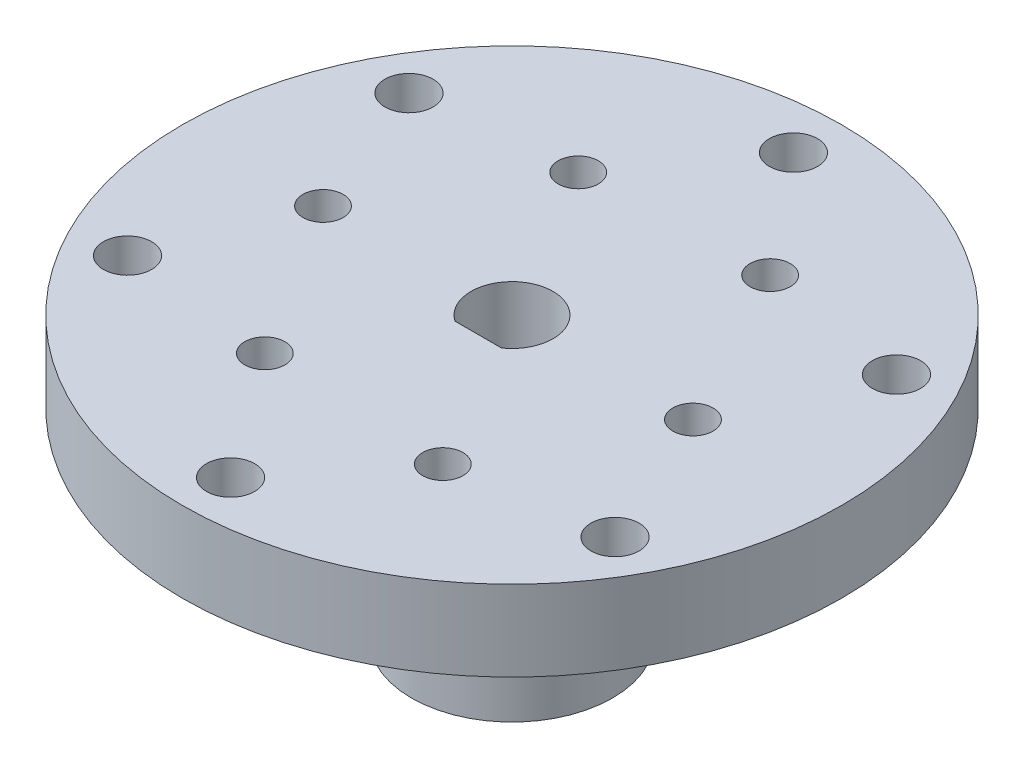
from build123d import *

# Parameters (mm, degrees)
SKETCH1_R               = 12.5
SKETCH1_R_2             = 5.1
BOSS_EXTRUDE1_DEPTH     = 15
SKETCH2_R               = 41
SKETCH2_R_2             = 5.1
BOSS_EXTRUDE2_DEPTH     = 20
SKETCH3_R               = 3
CUT_EXTRUDE1_DEPTH      = 36
BOSS_EXTRUDE3_DEPTH     = 35
SKETCH5_R               = 1.5
CUT_EXTRUDE2_DEPTH      = 46.2
CUT_EXTRUDE2_DEPTH_BACK = 37.8
SKETCH6_R               = 41
SKETCH6_R_2             = 12.5
CUT_EXTRUDE3_DEPTH      = 10
SKETCH8_R               = 2.5
CUT_EXTRUDE4_DEPTH      = 36.0000001


with BuildPart() as part:
    # Sketch1 → Boss-Extrude1 (new body)
    with BuildSketch(Plane(origin=(0, 0, 0), x_dir=(1, 0, 0), z_dir=(0, 1, 0))):
        Circle(SKETCH1_R)
        Circle(SKETCH1_R_2, mode=Mode.SUBTRACT)
    extrude(amount=BOSS_EXTRUDE1_DEPTH)

    # Sketch2 → Boss-Extrude2 (add)
    with BuildSketch(Plane(origin=(0, 15, 0), x_dir=(1, 0, 0), z_dir=(0, 1, 0))):
        Circle(SKETCH2_R)
        Circle(SKETCH2_R_2, mode=Mode.SUBTRACT)
    extrude(amount=BOSS_EXTRUDE2_DEPTH)

    # Sketch3 → Cut-Extrude1 (cut, through all)
    with BuildSketch(Plane(origin=(0, 35, 0), x_dir=(1, 0, 0), z_dir=(0, 1, 0))):
        with Locations((0, 35)):
            Circle(SKETCH3_R)
        with Locations((30.310889132, 17.5)):
            Circle(SKETCH3_R)
        with Locations((30.310889132, -17.5)):
            Circle(SKETCH3_R)
        with Locations((0, -35)):
            Circle(SKETCH3_R)
        with Locations((-30.310889132, -17.5)):
            Circle(SKETCH3_R)
        with Locations((-30.310889132, 17.5)):
            Circle(SKETCH3_R)
    extrude(amount=-CUT_EXTRUDE1_DEPTH, mode=Mode.SUBTRACT)

    # Sketch4 → Boss-Extrude3 (add)
    with BuildSketch(Plane.XZ):
        with BuildLine():
            ThreePointArc((2.893095228, 4.2), (0, 5.1), (-2.893095228, 4.2))
            Line((-2.893095228, 4.2), (2.893095228, 4.2))
        make_face()
    extrude(amount=-BOSS_EXTRUDE3_DEPTH)

    # Sketch5 → Cut-Extrude2 (cut, two sides)
    with BuildSketch(Plane(origin=(0, 0, 4.2), x_dir=(-1, 0, 0), z_dir=(0, 0, -1))) as cut_extrude2_sk:
        with Locations((0, 9)):
            Circle(SKETCH5_R)
    extrude(amount=CUT_EXTRUDE2_DEPTH, mode=Mode.SUBTRACT)
    extrude(cut_extrude2_sk.sketch, amount=-CUT_EXTRUDE2_DEPTH_BACK, mode=Mode.SUBTRACT)

    # Sketch6 → Cut-Extrude3 (cut)
    with BuildSketch(Plane.XZ.offset(-15)):
        Circle(SKETCH6_R)
        Circle(SKETCH6_R_2, mode=Mode.SUBTRACT)
    extrude(amount=-CUT_EXTRUDE3_DEPTH, mode=Mode.SUBTRACT)

    # Sketch8 → Cut-Extrude4 (cut, through all)
    with BuildSketch(Plane.XZ):
        with Locations((22.5, 0)):
            Circle(SKETCH8_R)
        with Locations((-23.5, 0)):
            Circle(SKETCH8_R)
        with Locations((-11.25, -19.485571585)):
            Circle(SKETCH8_R)
        with Locations((-11.25, 19.485571585)):
            Circle(SKETCH8_R)
        with Locations((11.75, 20.351596989)):
            Circle(SKETCH8_R)
        with Locations((11.75, -20.351596989)):
            Circle(SKETCH8_R)
    extrude(amount=-CUT_EXTRUDE4_DEPTH, mode=Mode.SUBTRACT)


solid = part.part
